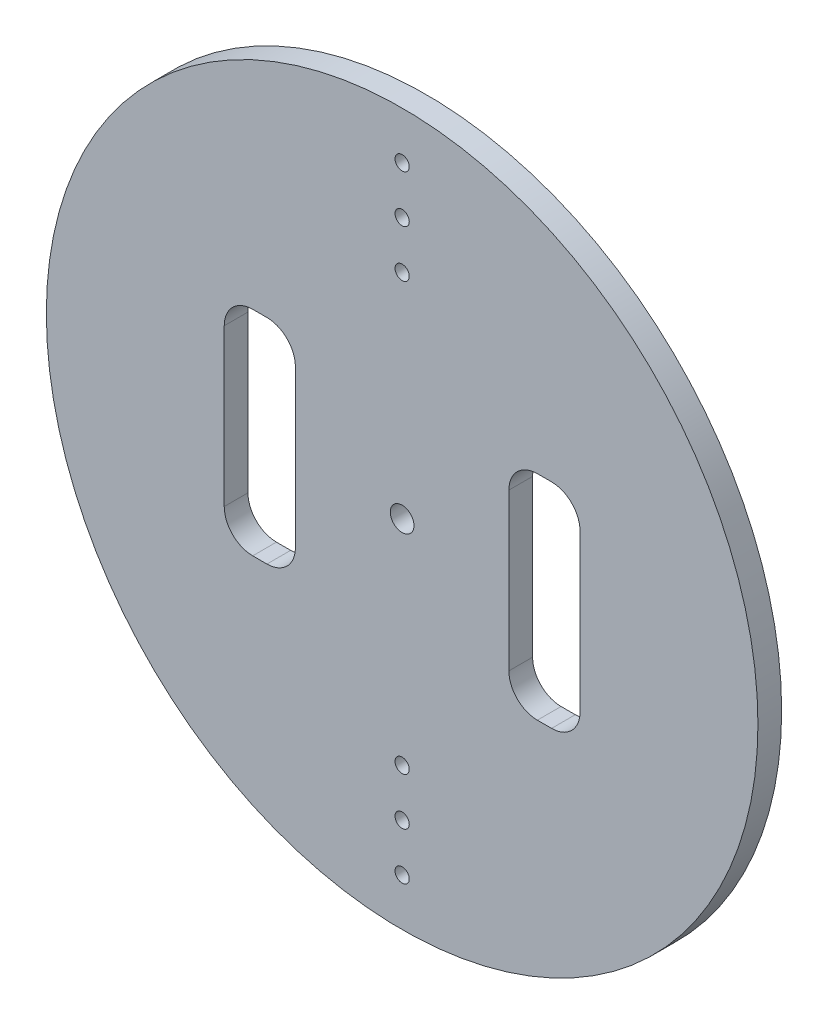
from build123d import *

# Parameters (mm, degrees)
ESBO_O1_R                = 75
RESSALTO_EXTRUS_O1_DEPTH = 5
ESBO_O2_R                = 2.5
CORTE_EXTRUS_O1_DEPTH    = 10
ESBO_O3_R                = 1.5
CORTE_EXTRUS_O2_DEPTH    = 10
CORTE_EXTRUS_O3_DEPTH    = 6


with BuildPart() as part:
    # Esboço1 → Ressalto-extrusão1 (new body)
    with BuildSketch(Plane.XY):
        Circle(ESBO_O1_R)
    extrude(amount=RESSALTO_EXTRUS_O1_DEPTH)

    # Esboço2 → Corte-extrusão1 (cut)
    with BuildSketch(Plane(origin=(0, 0, 0), x_dir=(-1, 0, 0), z_dir=(0, 0, -1))):
        Circle(ESBO_O2_R)
    extrude(amount=-CORTE_EXTRUS_O1_DEPTH, mode=Mode.SUBTRACT)

    # Esboço3 → Corte-extrusão2 (cut)
    with BuildSketch(Plane(origin=(0, 0, 0), x_dir=(-1, 0, 0), z_dir=(0, 0, -1))):
        with Locations((0, -45)):
            Circle(ESBO_O3_R)
        with Locations((0, -55)):
            Circle(ESBO_O3_R)
        with Locations((0, -65)):
            Circle(ESBO_O3_R)
        with Locations((0, 65)):
            Circle(ESBO_O3_R)
        with Locations((0, 55)):
            Circle(ESBO_O3_R)
        with Locations((0, 45)):
            Circle(ESBO_O3_R)
    extrude(amount=-CORTE_EXTRUS_O2_DEPTH, mode=Mode.SUBTRACT)

    # Esboço4 → Corte-extrusão3 (cut, through all)
    with BuildSketch(Plane(origin=(0, 0, 0), x_dir=(-1, 0, 0), z_dir=(0, 0, -1))):
        with BuildLine():
            Line((-31.5, -22.5), (-28.5, -22.5))
            ThreePointArc((-28.5, -22.5), (-24.257359313, -20.742640687), (-22.5, -16.5))
            Line((-22.5, -16.5), (-22.5, 16.5))
            ThreePointArc((-22.5, 16.5), (-24.257359313, 20.742640687), (-28.5, 22.5))
            Line((-28.5, 22.5), (-31.5, 22.5))
            ThreePointArc((-31.5, 22.5), (-35.742640687, 20.742640687), (-37.5, 16.5))
            Line((-37.5, 16.5), (-37.5, -16.5))
            ThreePointArc((-37.5, -16.5), (-35.742640687, -20.742640687), (-31.5, -22.5))
        make_face()
        with BuildLine():
            Line((28.5, -22.5), (31.5, -22.5))
            ThreePointArc((31.5, -22.5), (35.742640687, -20.742640687), (37.5, -16.5))
            Line((37.5, -16.5), (37.5, 16.5))
            ThreePointArc((37.5, 16.5), (35.742640687, 20.742640687), (31.5, 22.5))
            Line((31.5, 22.5), (28.5, 22.5))
            ThreePointArc((28.5, 22.5), (24.257359313, 20.742640687), (22.5, 16.5))
            Line((22.5, 16.5), (22.5, -16.5))
            ThreePointArc((22.5, -16.5), (24.257359313, -20.742640687), (28.5, -22.5))
        make_face()
    extrude(amount=-CORTE_EXTRUS_O3_DEPTH, mode=Mode.SUBTRACT)


solid = part.part
